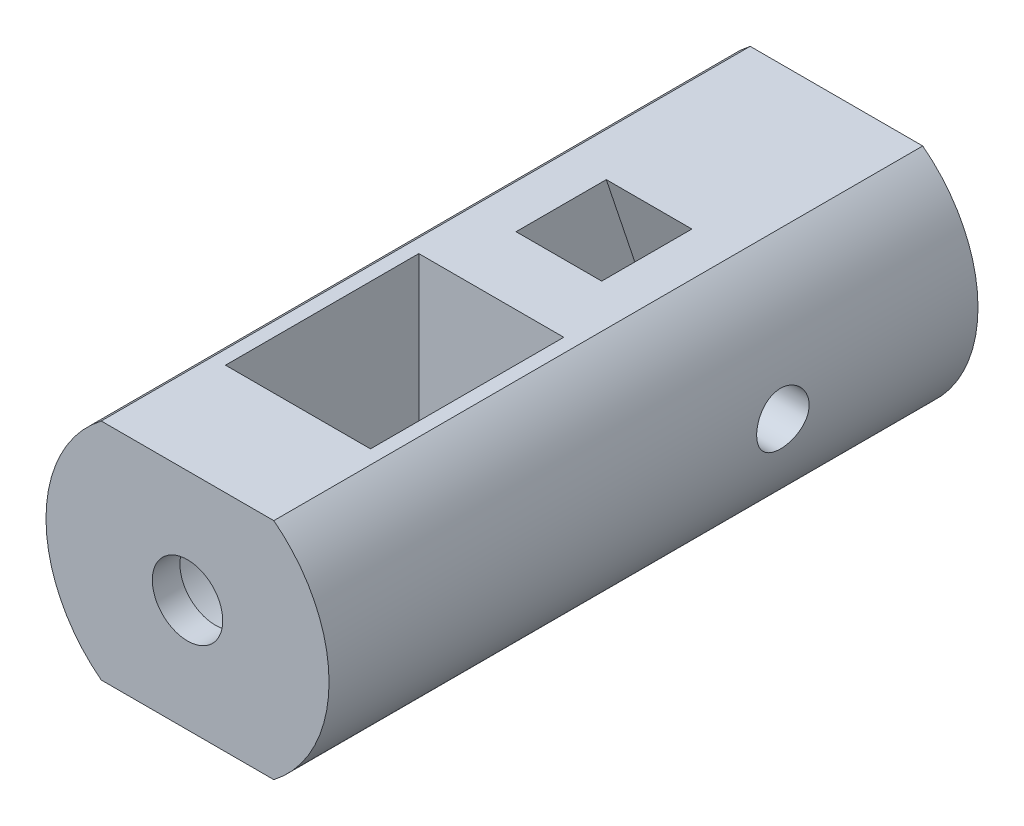
from build123d import *

# Parameters (mm, degrees)
SALIENTE_EXTRUIR1_DEPTH             = 47
CROQUIS2_W                          = 6.2
CROQUIS2_H                          = 6.535373831
CORTAR_EXTRUIR1_DEPTH               = 17.248076809
CROQUIS3_W                          = 10.5
CROQUIS3_H                          = 14
CORTAR_EXTRUIR2_DEPTH               = 17.248076809
NGULO_DE_SALIDA1_ANGLE              = 18.434948823
NGULO_DE_SALIDA2_ANGLE              = -18.434948823
TALADRO1_D                          = 5.1
TALADRO1_DEPTH                      = 8
TALADRO1_CBORE_D                    = 10.5
TALADRO1_CBORE_DEPTH                = 6
CROQUIS6_W                          = 1.9
CROQUIS6_H                          = 7.15
DI_METRO_DE_TALADRO_3_8_3_8_2_D     = 3.8
DI_METRO_DE_TALADRO_3_8_3_8_2_DEPTH = 7.15


with BuildPart() as part:
    # Croquis1 → Saliente-Extruir1 (new body)
    with BuildSketch(Plane(origin=(0, 0, 117.639), x_dir=(-1, 0, 0), z_dir=(0, 0, -1))):
        with BuildLine():
            Line((-6.25, 309.279690095), (6.25, 309.279690095))
            ThreePointArc((6.25, 309.279690095), (10.25, 317.403728499), (6.25, 325.527766904))
            Line((6.25, 325.527766904), (-6.25, 325.527766904))
            ThreePointArc((-6.25, 325.527766904), (-10.25, 317.403728499), (-6.25, 309.279690095))
        make_face()
    extrude(amount=-SALIENTE_EXTRUIR1_DEPTH)

    # Croquis2 → Cortar-Extruir1 (cut, through all)
    with BuildSketch(Plane(origin=(0, 325.527766904, 0), x_dir=(-1, 0, 0), z_dir=(0, 1, 0))):
        with Locations((0, 129.060696737)):
            Rectangle(CROQUIS2_W, CROQUIS2_H)
    extrude(amount=-CORTAR_EXTRUIR1_DEPTH, mode=Mode.SUBTRACT)

    # Croquis3 → Cortar-Extruir2 (cut, through all)
    with BuildSketch(Plane.XZ.offset(-309.279690095)):
        with Locations((0, 149.639)):
            Rectangle(CROQUIS3_W, CROQUIS3_H)
    extrude(amount=-CORTAR_EXTRUIR2_DEPTH, mode=Mode.SUBTRACT)

    # Ángulo de salida1
    ngulo_de_salida1_faces = [part.faces().sort_by_distance(p)[0] for p in [
        (0, 317.403728499, 125.793009821),
    ]]
    draft(ngulo_de_salida1_faces, Plane(origin=(6.25, 309.279690095, 164.639), x_dir=(0, 0, -1), z_dir=(0, -1, 0)), NGULO_DE_SALIDA1_ANGLE)

    # Ángulo de salida2
    ngulo_de_salida2_faces = [part.faces().sort_by_distance(p)[0] for p in [
        (0, 317.403728499, 132.328383652),
    ]]
    draft(ngulo_de_salida2_faces, Plane(origin=(6.25, 309.279690095, 164.639), x_dir=(0, 0, -1), z_dir=(0, -1, 0)), NGULO_DE_SALIDA2_ANGLE)

    # Taladro1
    with Locations(Plane(origin=(0, 0, 156.639), x_dir=(-1, 0, 0), z_dir=(0, 0, -1))):
        with Locations((0, 317.403728499)):
            CounterBoreHole(TALADRO1_D / 2, TALADRO1_CBORE_D / 2, TALADRO1_CBORE_DEPTH, depth=TALADRO1_DEPTH)

    # Croquis6 → Diámetro de taladro Ø3.8 (3.8)1 (revolve, cut)
    with BuildSketch(Plane(origin=(3.1, 317.403728499, 131.768709538), x_dir=(0, 0, 1), z_dir=(0, 1, 0))):
        with Locations((0.95, 3.575)):
            Rectangle(CROQUIS6_W, CROQUIS6_H)
    revolve(axis=Axis((-3.25, 317.403728499, 131.768709538), (1, 0, 0)), mode=Mode.SUBTRACT)

    # Diámetro de taladro Ø3.8 (3.8)2
    with Locations(Plane(origin=(-3.1, 0, 0), x_dir=(0, 0, -1), z_dir=(1, 0, 0))):
        with Locations((-131.768709538, 317.403728499)):
            Hole(DI_METRO_DE_TALADRO_3_8_3_8_2_D / 2, depth=DI_METRO_DE_TALADRO_3_8_3_8_2_DEPTH)


solid = part.part
